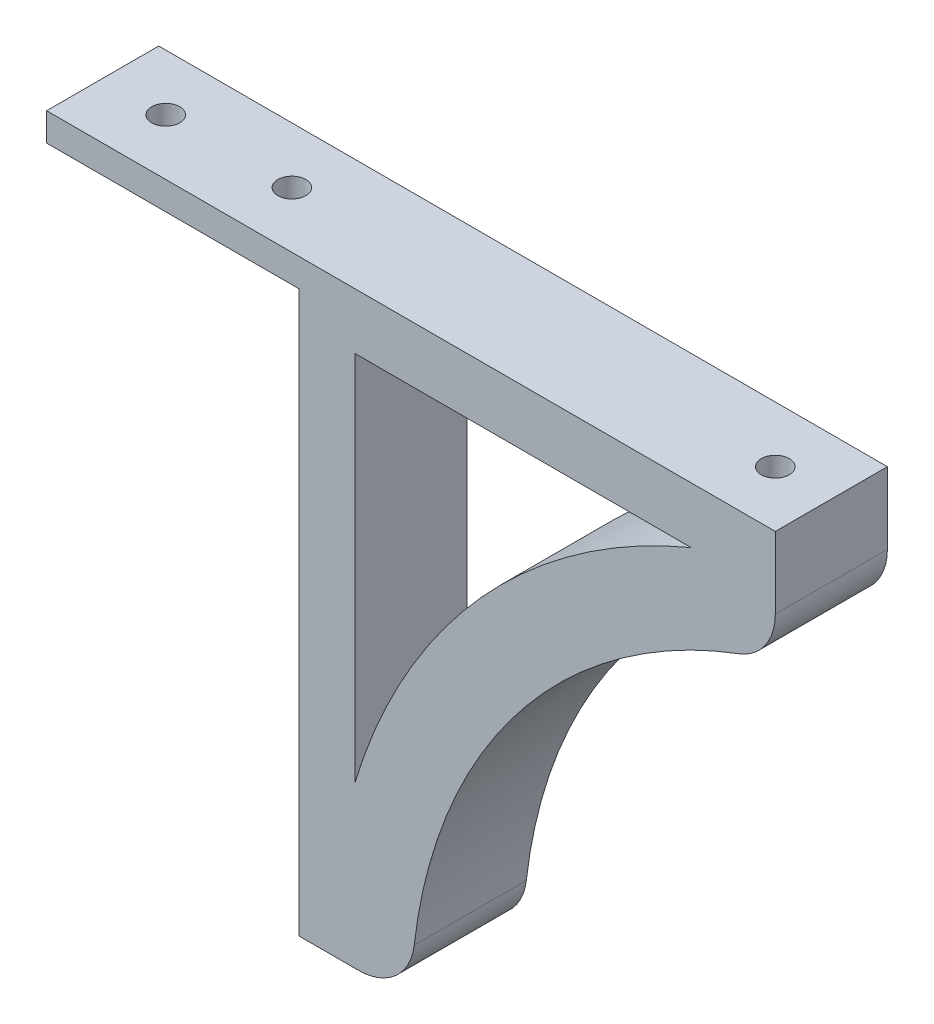
from build123d import *

# Parameters (mm, degrees)
BOSS_EXTRU_1_DEPTH           = 20
CONG_1_R                     = 10
CONG_2_R                     = 10
ESQUISSE3_R                  = 2.5
ENL_V_MAT_EXTRU_1_DEPTH      = 20
ESQUISSE4_R                  = 2.5
ENL_V_MAT_EXTRU_2_DEPTH      = 106
ESQUISSE5_R                  = 4.2
ENL_V_MAT_EXTRU_3_DEPTH      = 3
ENL_V_MAT_EXTRU_3_DEPTH_BACK = 13


with BuildPart() as part:
    # Esquisse2 → Boss.-Extru.1 (new body)
    with BuildSketch(Plane.XY):
        with BuildLine():
            Line((0, 0), (45, 0))
            Line((45, 0), (45, -100))
            Line((45, -100), (65, -100))
            ThreePointArc((65, -100), (83.49592747, -46.791003359), (130, -15))
            Line((130, -15), (130, 5))
            Line((130, 5), (0, 5))
            Line((0, 5), (0, 0))
        make_face()
        with BuildLine():
            Line((115, -5), (55, -5))
            Line((55, -5), (55, -71.357566363))
            ThreePointArc((55, -71.357566363), (77.53382116, -31.427921826), (115, -5))
        make_face(mode=Mode.SUBTRACT)
    extrude(amount=BOSS_EXTRU_1_DEPTH)

    # Congé1
    cong_1_edges = [part.edges().sort_by_distance(p)[0] for p in [
        (130, -15, 10),
    ]]
    fillet(cong_1_edges, radius=CONG_1_R)

    # Congé2
    cong_2_edges = [part.edges().sort_by_distance(p)[0] for p in [
        (65, -100, 10),
    ]]
    fillet(cong_2_edges, radius=CONG_2_R)

    # Esquisse3 → Enlèv. mat.-Extru.1 (cut)
    with BuildSketch(Plane.XZ):
        with Locations((33.75, 10)):
            Circle(ESQUISSE3_R)
        with Locations((11.25, 10)):
            Circle(ESQUISSE3_R)
    extrude(amount=-ENL_V_MAT_EXTRU_1_DEPTH, mode=Mode.SUBTRACT)

    # Esquisse4 → Enlèv. mat.-Extru.2 (cut, through all)
    with BuildSketch(Plane(origin=(0, 5, 0), x_dir=(1, 0, 0), z_dir=(0, 1, 0))):
        with Locations((120, -10)):
            Circle(ESQUISSE4_R)
    extrude(amount=-ENL_V_MAT_EXTRU_2_DEPTH, mode=Mode.SUBTRACT)

    # Esquisse5 → Enlèv. mat.-Extru.3 (cut, two sides)
    with BuildSketch(Plane(origin=(0, -17.190046968, 0), x_dir=(1, 0, 0), z_dir=(0, 1, 0))) as enl_v_mat_extru_3_sk:
        with Locations((120, -10)):
            Circle(ESQUISSE5_R)
    extrude(amount=ENL_V_MAT_EXTRU_3_DEPTH, mode=Mode.SUBTRACT)
    extrude(enl_v_mat_extru_3_sk.sketch, amount=-ENL_V_MAT_EXTRU_3_DEPTH_BACK, mode=Mode.SUBTRACT)


solid = part.part
